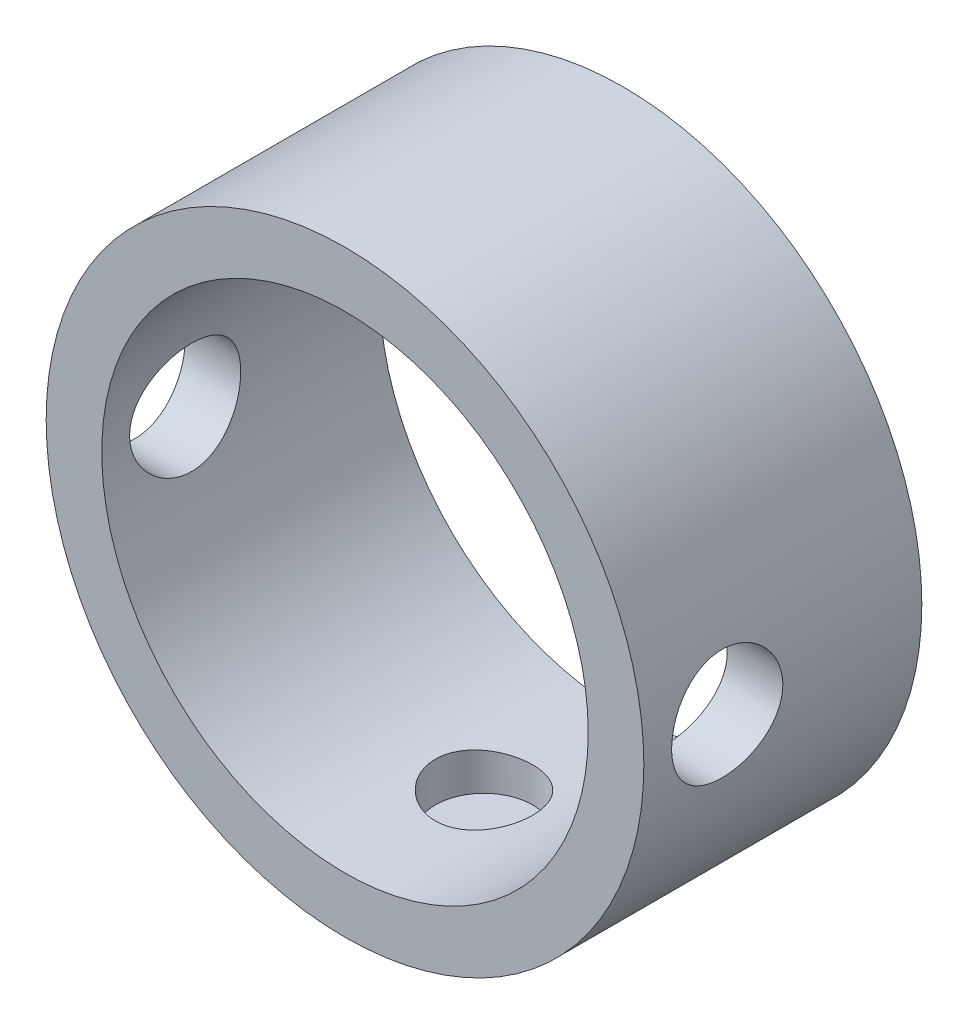
from build123d import *

# Parameters (mm, degrees)
ESQUISSE1_R             = 10.75
ESQUISSE1_R_2           = 8.75
BOSS_EXTRU_1_DEPTH      = 10
ESQUISSE2_R             = 1.75
ENL_V_MAT_EXTRU_1_DEPTH = 10
ESQUISSE3_R             = 2
ENL_V_MAT_EXTRU_2_DEPTH = 15


with BuildPart() as part:
    # Esquisse1 → Boss.-Extru.1 (new body)
    with BuildSketch(Plane.XY):
        Circle(ESQUISSE1_R)
        Circle(ESQUISSE1_R_2, mode=Mode.SUBTRACT)
    extrude(amount=BOSS_EXTRU_1_DEPTH)

    # Esquisse2 → Enlèv. mat.-Extru.1 (cut)
    with BuildSketch(Plane(origin=(0, 0, 0), x_dir=(1, 0, 0), z_dir=(0, 1, 0))):
        with Locations((0, -5)):
            Circle(ESQUISSE2_R)
    extrude(amount=-ENL_V_MAT_EXTRU_1_DEPTH, mode=Mode.SUBTRACT)

    # Esquisse3 → Enlèv. mat.-Extru.2 (cut, symmetric)
    with BuildSketch(Plane(origin=(0, 0, 0), x_dir=(0, 0, -1), z_dir=(1, 0, 0))):
        with Locations((-7, 0)):
            Circle(ESQUISSE3_R)
    extrude(amount=ENL_V_MAT_EXTRU_2_DEPTH, both=True, mode=Mode.SUBTRACT)


solid = part.part
